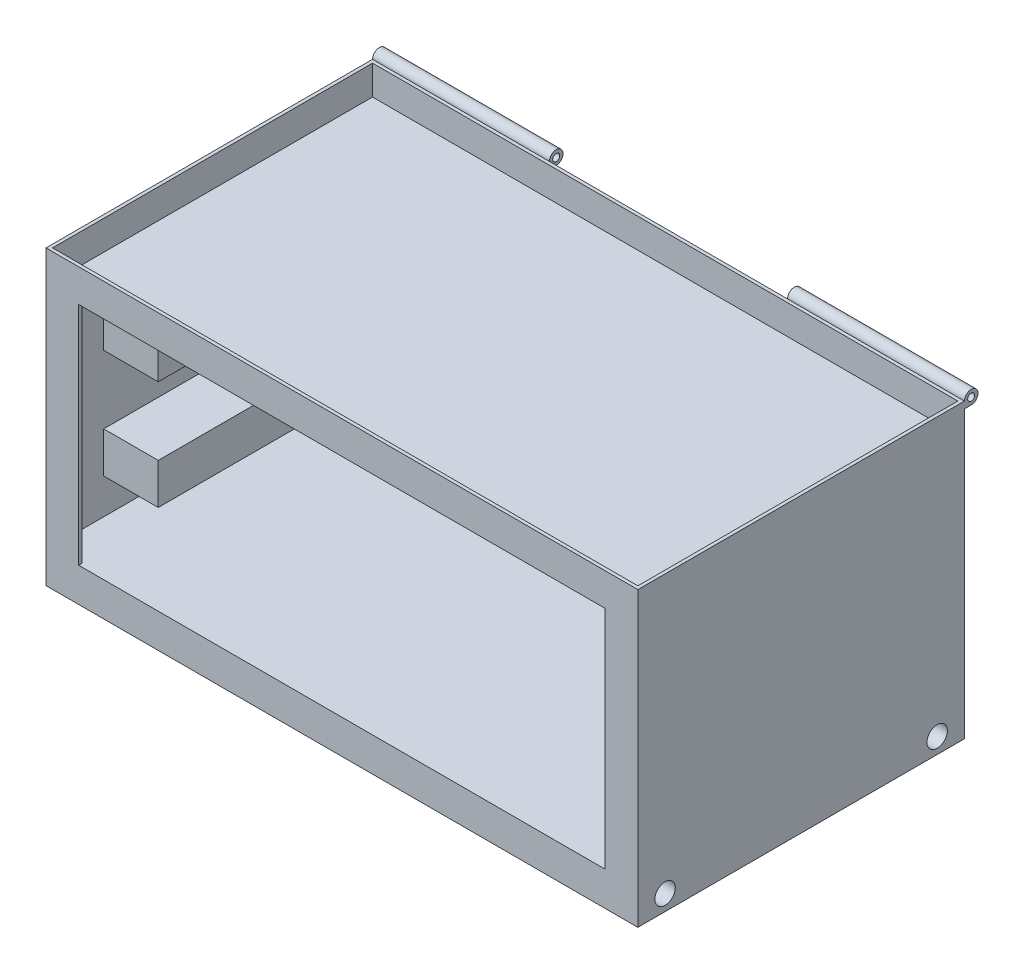
from build123d import *

# Parameters (mm, degrees)
SKETCH1_W               = 276.225
SKETCH1_H               = 152.4
BULK_EXTRUDE_DEPTH      = 136.525
SKETCH1_13_W            = 273.177
SKETCH1_13_H            = 149.352
SKETCH1_13_W_2          = 245.745
SKETCH1_13_H_2          = 1.524
INNER_SHELL_CUT_DEPTH   = 120.65
SKETCH1_14_W            = 245.745
SKETCH1_14_H            = 1.524
TOP_WALL_EXTRUDE_DEPTH  = 15.24
TOP_START               = -15.24
SKETCH1_15_W            = 273.177
SKETCH1_15_H            = 149.352
TOP_FLOOR_EXTRUDE_DEPTH = 1.524
SKETCH5_R               = 1.651
HINGE_EXTRUDE_DEPTH     = 82.55
SKETCH7_W               = 25.4635
SKETCH7_H               = 19.05
RAILS_EXTRUDE_DEPTH     = 125.476
SKETCH8_R               = 4.7625
CUT_EXTRUDE1_DEPTH      = 346.918113614
CUT_EXTRUDE1_DEPTH_BACK = 346.918113614


with BuildPart() as part:
    # Sketch1 → Bulk-Extrude (new body)
    with BuildSketch(Plane(origin=(0, 0, 0), x_dir=(1, 0, 0), z_dir=(0, 1, 0))):
        with Locations((136.5885, 74.676)):
            Rectangle(SKETCH1_W, SKETCH1_H)
    extrude(amount=-BULK_EXTRUDE_DEPTH)

    # Sketch1_13 → Inner Shell-Cut (cut)
    with BuildSketch(Plane(origin=(0, 0, 0), x_dir=(1, 0, 0), z_dir=(0, 1, 0))):
        with Locations((136.5885, 74.676)):
            Rectangle(SKETCH1_13_W, SKETCH1_13_H)
        with Locations((136.5885, -0.762)):
            Rectangle(SKETCH1_13_W_2, SKETCH1_13_H_2)
    extrude(amount=-INNER_SHELL_CUT_DEPTH, mode=Mode.SUBTRACT)

    # Sketch1_14 → Top Wall-Extrude (add)
    with BuildSketch(Plane(origin=(0, 0, 0), x_dir=(1, 0, 0), z_dir=(0, 1, 0))):
        with Locations((136.5885, -0.762)):
            Rectangle(SKETCH1_14_W, SKETCH1_14_H)
    extrude(amount=-TOP_WALL_EXTRUDE_DEPTH)

    # Sketch1_15 → Top Floor-Extrude (add)
    with BuildSketch(Plane(origin=(0, 0, 0), x_dir=(1, 0, 0), z_dir=(0, 1, 0)).offset(TOP_START)):
        with Locations((136.5885, 74.676)):
            Rectangle(SKETCH1_15_W, SKETCH1_15_H)
    extrude(amount=TOP_FLOOR_EXTRUDE_DEPTH)

    # Sketch5 → Hinge-Extrude (add)
    with BuildSketch(Plane(origin=(274.701, 0, 0), x_dir=(0, 0, -1), z_dir=(1, 0, 0))):
        with BuildLine():
            Line((150.876, 0), (150.876, -3.175))
            Line((150.876, -3.175), (154.051, -3.175))
            ThreePointArc((154.051, -3.175), (156.29606403, 2.24506403), (150.876, 0))
        make_face()
        with Locations((154.051, 0)):
            Circle(SKETCH5_R, mode=Mode.SUBTRACT)
    hinge_extrude = extrude(amount=-HINGE_EXTRUDE_DEPTH)

    # Mirror1: Hinge-Extrude across plane
    add(hinge_extrude.mirror(Plane(origin=(136.5885, 0, 0), x_dir=(0, 0, 1), z_dir=(1, 0, 0))))

    # Sketch7 → Rails-Extrude (add)
    with BuildSketch(Plane.XY.offset(-149.352)):
        with Locations((12.73175, -43.815)):
            Rectangle(SKETCH7_W, SKETCH7_H)
        with Locations((260.44525, -43.815)):
            Rectangle(SKETCH7_W, SKETCH7_H)
        with Locations((12.73175, -94.615)):
            Rectangle(SKETCH7_W, SKETCH7_H)
        with Locations((260.44525, -94.615)):
            Rectangle(SKETCH7_W, SKETCH7_H)
    extrude(amount=RAILS_EXTRUDE_DEPTH)

    # Sketch8 → Cut-Extrude1 (cut, two sides)
    with BuildSketch(Plane(origin=(274.701, 0, 0), x_dir=(0, 0, -1), z_dir=(1, 0, 0))) as cut_extrude1_sk:
        with Locations((11.176, -129.2098)):
            Circle(SKETCH8_R)
        with Locations((138.176, -129.2098)):
            Circle(SKETCH8_R)
    extrude(amount=CUT_EXTRUDE1_DEPTH, mode=Mode.SUBTRACT)
    extrude(cut_extrude1_sk.sketch, amount=-CUT_EXTRUDE1_DEPTH_BACK, mode=Mode.SUBTRACT)


solid = part.part
